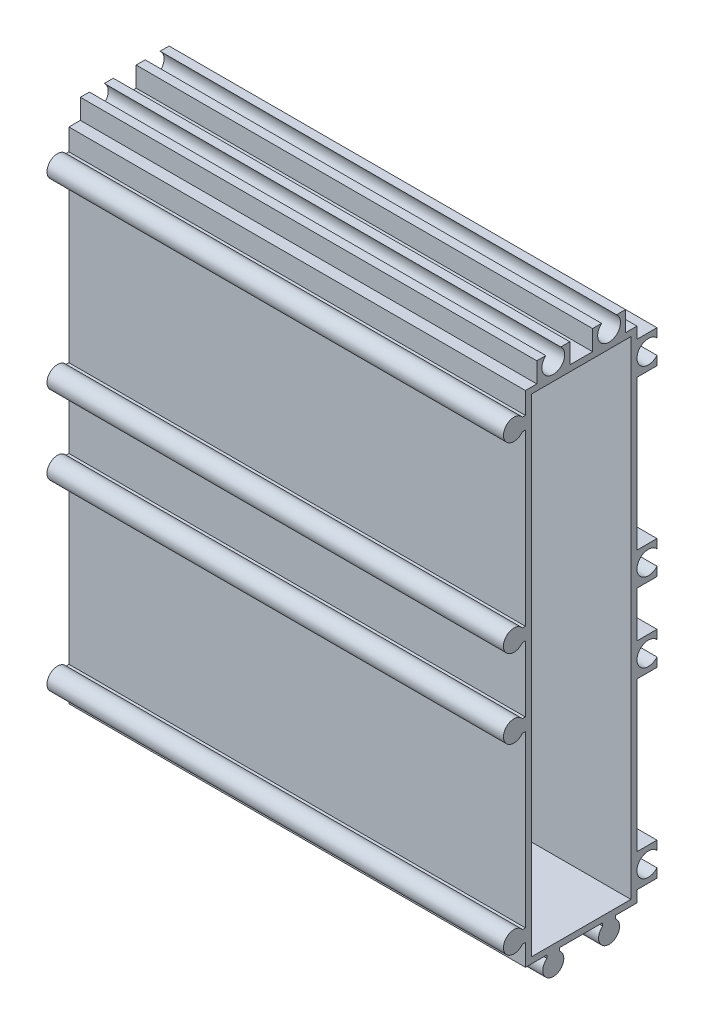
from build123d import *

# Parameters (mm, degrees)
EXTRUDE_1_DEPTH             = 90
SKETCH_2_W                  = 90
SKETCH_2_H                  = 17.75
EXTRUDE_2_DEPTH             = 8.2
SKETCH_3_W                  = 90
SKETCH_3_H                  = 102.45
EXTRUDE_3_DEPTH             = 8.2
SKETCH_4_W                  = 3.95
SKETCH_4_H                  = 2.25
CUT_EXTRUDE_1_DEPTH         = 91
SKETCH_5_W                  = 3.95
SKETCH_5_H                  = 29.5
CUT_EXTRUDE_2_DEPTH         = 91
SKETCH_6_W                  = 3.95
SKETCH_6_H                  = 9
CUT_EXTRUDE_3_DEPTH         = 91
SKETCH_7_W                  = 3.95
SKETCH_7_H                  = 29.5
CUT_EXTRUDE_4_DEPTH         = 91
SKETCH_8_W                  = 3.95
SKETCH_8_H                  = 6.2
CUT_EXTRUDE_5_DEPTH         = 91
SKETCH_9_W                  = 2.25
SKETCH_9_H                  = 3.95
CUT_EXTRUDE_6_DEPTH         = 91
SKETCH_10_W                 = 4.5
SKETCH_10_H                 = 3.95
CUT_EXTRUDE_7_DEPTH         = 91
SKETCH_11_W                 = 2.25
SKETCH_11_H                 = 3.95
CUT_EXTRUDE_8_DEPTH         = 91
SKETCH_12_W                 = 19.6
SKETCH_12_H                 = 96.1
CUT_EXTRUDE_9_DEPTH         = 86.2
HOLE_WIZARD_4_5_4_5_1_D     = 4.5
HOLE_WIZARD_4_5_4_5_1_DEPTH = 90
HOLE_WIZARD_2_5_2_5_1_D     = 2.5
HOLE_WIZARD_2_5_2_5_1_DEPTH = 90
SKETCH_20_R                 = 1.649948342
SKETCH_20_R_2               = 1.660581376
SKETCH_20_R_3               = 1.430745594
SKETCH_20_R_4               = 1.573250385
SKETCH_20_R_5               = 1.502029841
SKETCH_20_R_6               = 1.53795619
EXTRUDE_5_DEPTH             = 90


with BuildPart() as part:
    # Эскиз1 → Бобышка-Вытянуть1 (new body)
    with BuildSketch(Plane(origin=(90, 0, 0), x_dir=(0, 0, -1), z_dir=(1, 0, 0))):
        with BuildLine():
            Line((6.75, 40.906238208), (6.75, 135.75))
            Line((6.75, 135.75), (-11.593761792, 135.75))
            ThreePointArc((-11.593761792, 135.75), (-15.325, 134.5), (-11.593761793, 133.25))
            Line((-11.593761793, 133.25), (-11, 133.25))
            Line((-11, 133.25), (-11, 99.75))
            Line((-11, 99.75), (-11.593761792, 99.75))
            ThreePointArc((-11.593761792, 99.75), (-15.325, 98.5), (-11.593761792, 97.25))
            Line((-11.593761792, 97.25), (-11, 97.25))
            Line((-11, 97.25), (-11, 84.25))
            Line((-11, 84.25), (-11.593761792, 84.25))
            ThreePointArc((-11.593761792, 84.25), (-15.325, 83), (-11.593761792, 81.75))
            Line((-11.593761792, 81.75), (-11, 81.75))
            Line((-11, 81.75), (-11, 48.25))
            Line((-11, 48.25), (-11.593761792, 48.25))
            ThreePointArc((-11.593761792, 48.25), (-15.325, 47), (-11.593761792, 45.75))
            Line((-11.593761792, 45.75), (-11, 45.75))
            Line((-11, 45.75), (-11, 41.5))
            Line((-11, 41.5), (-6.75, 41.5))
            Line((-6.75, 41.5), (-6.75, 40.906238208))
            ThreePointArc((-6.75, 40.906238208), (-5.5, 37.175), (-4.25, 40.906238208))
            Line((-4.25, 40.906238208), (-4.25, 41.5))
            Line((-4.25, 41.5), (4.25, 41.5))
            Line((4.25, 41.5), (4.25, 40.906238208))
            ThreePointArc((4.25, 40.906238208), (5.5, 37.175), (6.75, 40.906238208))
        make_face()
    extrude(amount=-EXTRUDE_1_DEPTH)

    # Эскиз2 → Бобышка-Вытянуть2 (add)
    with BuildSketch(Plane(origin=(0, 135.75, 0), x_dir=(-1, 0, 0), z_dir=(0, 1, 0))):
        with Locations((-45, 2.125)):
            Rectangle(SKETCH_2_W, SKETCH_2_H)
    extrude(amount=EXTRUDE_2_DEPTH)

    # Эскиз3 → Бобышка-Вытянуть3 (add)
    with BuildSketch(Plane(origin=(0, 0, -6.75), x_dir=(-1, 0, 0), z_dir=(0, 0, -1))):
        with Locations((-45, 92.725)):
            Rectangle(SKETCH_3_W, SKETCH_3_H)
    extrude(amount=EXTRUDE_3_DEPTH)

    # Эскиз4 → Вырез-Вытянуть1 (cut, through all)
    with BuildSketch(Plane.ZY):
        with Locations((-12.975, 42.625)):
            Rectangle(SKETCH_4_W, SKETCH_4_H)
    extrude(amount=-CUT_EXTRUDE_1_DEPTH, mode=Mode.SUBTRACT)

    # Эскиз5 → Вырез-Вытянуть2 (cut, through all)
    with BuildSketch(Plane.ZY):
        with Locations((-12.975, 65)):
            Rectangle(SKETCH_5_W, SKETCH_5_H)
    extrude(amount=-CUT_EXTRUDE_2_DEPTH, mode=Mode.SUBTRACT)

    # Эскиз6 → Вырез-Вытянуть3 (cut, through all)
    with BuildSketch(Plane.ZY):
        with Locations((-12.975, 90.75)):
            Rectangle(SKETCH_6_W, SKETCH_6_H)
    extrude(amount=-CUT_EXTRUDE_3_DEPTH, mode=Mode.SUBTRACT)

    # Эскиз7 → Вырез-Вытянуть4 (cut, through all)
    with BuildSketch(Plane.ZY):
        with Locations((-12.975, 116.5)):
            Rectangle(SKETCH_7_W, SKETCH_7_H)
    extrude(amount=-CUT_EXTRUDE_4_DEPTH, mode=Mode.SUBTRACT)

    # Эскиз8 → Вырез-Вытянуть5 (cut, through all)
    with BuildSketch(Plane.ZY):
        with Locations((-12.975, 140.85)):
            Rectangle(SKETCH_8_W, SKETCH_8_H)
    extrude(amount=-CUT_EXTRUDE_5_DEPTH, mode=Mode.SUBTRACT)

    # Эскиз9 → Вырез-Вытянуть6 (cut, through all)
    with BuildSketch(Plane.ZY):
        with Locations((-9.875, 141.975)):
            Rectangle(SKETCH_9_W, SKETCH_9_H)
    extrude(amount=-CUT_EXTRUDE_6_DEPTH, mode=Mode.SUBTRACT)

    # Эскиз10 → Вырез-Вытянуть7 (cut, through all)
    with BuildSketch(Plane.ZY):
        with Locations((0, 141.975)):
            Rectangle(SKETCH_10_W, SKETCH_10_H)
    extrude(amount=-CUT_EXTRUDE_7_DEPTH, mode=Mode.SUBTRACT)

    # Эскиз11 → Вырез-Вытянуть8 (cut, through all)
    with BuildSketch(Plane.ZY):
        with Locations((9.875, 141.975)):
            Rectangle(SKETCH_11_W, SKETCH_11_H)
    extrude(amount=-CUT_EXTRUDE_8_DEPTH, mode=Mode.SUBTRACT)

    # Эскиз12 → Вырез-Вытянуть9 (cut)
    with BuildSketch(Plane(origin=(90, 0, 0), x_dir=(0, 0, -1), z_dir=(1, 0, 0))):
        with Locations((0, 90.75)):
            Rectangle(SKETCH_12_W, SKETCH_12_H)
    extrude(amount=-CUT_EXTRUDE_9_DEPTH, mode=Mode.SUBTRACT)

    # Диаметр отверстия Ø4.5 (4.5)1
    with Locations(Plane.ZY):
        with Locations((-13.25, 47), (-13.25, 83), (-13.25, 98.5), (-13.25, 134.5), (-5.5, 142.25), (5.5, 142.25)):
            Hole(HOLE_WIZARD_4_5_4_5_1_D / 2, depth=HOLE_WIZARD_4_5_4_5_1_DEPTH)

    # Диаметр отверстия Ø2.5 (2.5)1
    with Locations(Plane(origin=(90, 0, 0), x_dir=(0, 0, -1), z_dir=(1, 0, 0))):
        with Locations((-13.25, 98.5), (-13.25, 134.5), (-13.25, 47), (-13.25, 83), (5.5, 39.25), (-5.5, 39.25)):
            Hole(HOLE_WIZARD_2_5_2_5_1_D / 2, depth=HOLE_WIZARD_2_5_2_5_1_DEPTH)

    # Эскиз20 → Бобышка-Вытянуть5 (add)
    with BuildSketch(Plane(origin=(90, 0, 0), x_dir=(0, 0, -1), z_dir=(1, 0, 0))):
        with Locations((-13.25, 134.5)):
            Circle(SKETCH_20_R)
        with Locations((-13.25, 98.5)):
            Circle(SKETCH_20_R_2)
        with Locations((-13.25, 83)):
            Circle(SKETCH_20_R_3)
        with Locations((-13.25, 47)):
            Circle(SKETCH_20_R_4)
        with Locations((-5.5, 39.25)):
            Circle(SKETCH_20_R_5)
        with Locations((5.5, 39.25)):
            Circle(SKETCH_20_R_6)
    extrude(amount=-EXTRUDE_5_DEPTH)


solid = part.part
